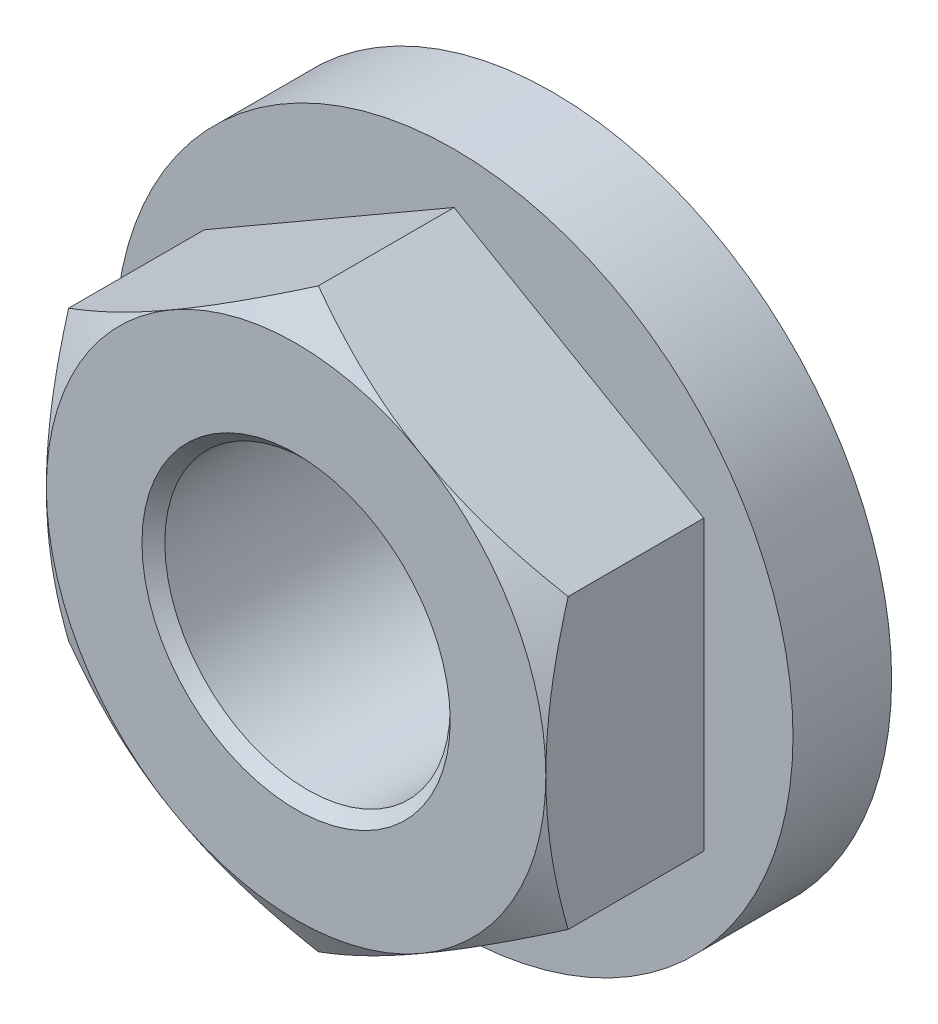
from build123d import *

# Parameters (mm, degrees)
EXTRUDE1_DEPTH         = 5.953125
SKETCH13_R             = 7.540625
EXTRUDE3_DEPTH         = 2.4384
SKETCH2_OUTSIDE_W      = 67.282
SKETCH2_OUTSIDE_H      = 67.282
SKETCH2_OUTSIDE_R      = 5.55625
CUT_EXTRUDE1_DEPTH     = 13.213179277
CUT_EXTRUDE1_DRAFT     = -60
SKETCH4_R              = 3.175
CUT_EXTRUDE3_DEPTH     = 13.213179277
CUT_SWEEP1_PITCH       = 1.27
CUT_SWEEP1_HEIGHT      = 7.223125
CUT_SWEEP1_RADIUS      = 3.175
CUT_SWEEP1_START_ANGLE = 90
SKETCH14_OUTSIDE_W     = 21.51
SKETCH14_OUTSIDE_H     = 21.51
SKETCH14_OUTSIDE_R     = 5.461
CUT_EXTRUDE8_DEPTH     = 0.24384


with BuildPart() as part:
    # Sketch1 → Extrude1 (new body)
    with BuildSketch(Plane.XY):
        Polygon((0, 6.415804866), (-5.55625, 3.207902433), (-5.55625, -3.207902433), (0, -6.415804866), (5.55625, -3.207902433), (5.55625, 3.207902433), align=None)
    extrude(amount=-EXTRUDE1_DEPTH)

    # Sketch13 → Extrude3 (add)
    with BuildSketch(Plane(origin=(0, 0, -5.953125), x_dir=(-1, 0, 0), z_dir=(0, 0, -1))):
        Circle(SKETCH13_R)
    extrude(amount=-EXTRUDE3_DEPTH)


with BuildPart() as cut_extrude1_tool:
    # Sketch2 outside → Cut-Extrude1 (with draft: the straight prism first)
    with BuildSketch(Plane.XY):
        Rectangle(SKETCH2_OUTSIDE_W, SKETCH2_OUTSIDE_H)
        Circle(SKETCH2_OUTSIDE_R, mode=Mode.SUBTRACT)
    extrude(amount=-CUT_EXTRUDE1_DEPTH)
    # Cut-Extrude1: the draft: its side faces are tilted about the plane it starts from
    cut_extrude1_sides = [cut_extrude1_tool.faces().sort_by_distance(p)[0] for p in [
        (0, -33.641, -6.606589638),
        (33.641, 0, -6.606589638),
        (0, 33.641, -6.606589638),
        (-33.641, 0, -6.606589638),
        (-5.55625, 0, -6.606589638),
    ]]
    draft(cut_extrude1_sides, Plane.XY, CUT_EXTRUDE1_DRAFT)


with BuildPart() as part_1:
    add(part.part)

    # Cut-Extrude1: cut by cut_extrude1_tool
    add(cut_extrude1_tool.part, mode=Mode.SUBTRACT)

    # Sketch4 → Cut-Extrude3 (cut, through all)
    with BuildSketch(Plane.XY):
        Circle(SKETCH4_R)
    extrude(amount=-CUT_EXTRUDE3_DEPTH, mode=Mode.SUBTRACT)

    # Cut-Sweep1: sweep along a helix
    with BuildLine() as cut_sweep1_path:
        add(Helix(CUT_SWEEP1_PITCH, CUT_SWEEP1_HEIGHT, CUT_SWEEP1_RADIUS, center=(0, 0, 0), direction=(0, 0, -1), mode=Mode.PRIVATE).rotate(Axis((0, 0, 0), (0, 0, -1)), CUT_SWEEP1_START_ANGLE))
    # Sketch9 → Cut-Sweep1 (sweep, cut)
    with BuildSketch(Plane(origin=(0, 0, 0), x_dir=(0, 0, -1), z_dir=(1, 0, 0))):
        Polygon((-0.635, 3.175), (-0.47625, 3.175), (0, 2.350110803), (-1.11125, 2.350110803), align=None)
    sweep(path=cut_sweep1_path.line, is_frenet=True, mode=Mode.SUBTRACT)

    # Cut-Extrude6 cone 1 section (through the dimple's axis) → Cut-Extrude6 (revolve, cut)
    with BuildSketch(Plane(origin=(0, 0, 0), x_dir=(0, -1, 0), z_dir=(1, 0, 0))):
        Polygon((0, 0), (3.429, 0), (0, 3.429), align=None)
    revolve(axis=Axis((0, 0, 0), (0, 0, -1)), mode=Mode.SUBTRACT)

    # Cut-Extrude7 cone 1 section (through the dimple's axis) → Cut-Extrude7 (revolve, cut)
    with BuildSketch(Plane(origin=(0, 0, -5.953125), x_dir=(0, 1, 0), z_dir=(1, 0, 0))):
        Polygon((0, 0), (3.429, 0), (0, 3.429), align=None)
    revolve(axis=Axis((0, 0, -5.953125), (0, 0, 1)), mode=Mode.SUBTRACT)

    # Sketch14 outside → Cut-Extrude8 (cut)
    with BuildSketch(Plane(origin=(0, 0, -5.953125), x_dir=(-1, 0, 0), z_dir=(0, 0, -1))):
        Rectangle(SKETCH14_OUTSIDE_W, SKETCH14_OUTSIDE_H)
        Circle(SKETCH14_OUTSIDE_R, mode=Mode.SUBTRACT)
    extrude(amount=-CUT_EXTRUDE8_DEPTH, mode=Mode.SUBTRACT)


solid = part_1.part
